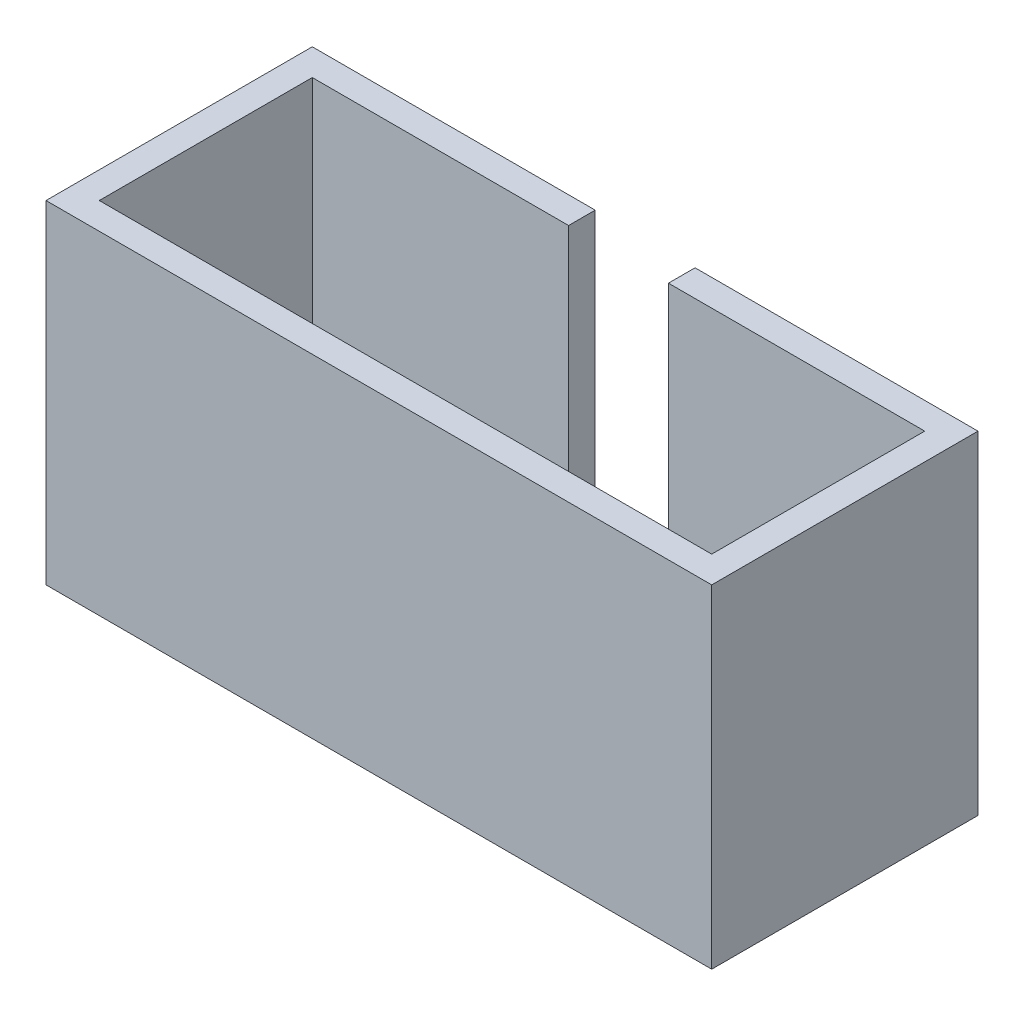
from build123d import *

# Parameters (mm, degrees)
SKETCH1_W           = 20
SKETCH1_H           = 8
SKETCH1_W_2         = 18.4
SKETCH1_H_2         = 6.4
BOSS_EXTRUDE1_DEPTH = 10
SKETCH3_W           = 18.4
SKETCH3_H           = 6.4
BOSS_EXTRUDE2_DEPTH = 0.8
CUT_EXTRUDE1_REACH  = 10
SKETCH2_W           = 3
SKETCH2_H           = 8


with BuildPart() as part:
    # Sketch1 → Boss-Extrude1 (new body)
    with BuildSketch(Plane(origin=(0, 0, 0), x_dir=(1, 0, 0), z_dir=(0, 1, 0))):
        Rectangle(SKETCH1_W, SKETCH1_H)
        Rectangle(SKETCH1_W_2, SKETCH1_H_2, mode=Mode.SUBTRACT)
    extrude(amount=BOSS_EXTRUDE1_DEPTH)

    # Sketch3 → Boss-Extrude2 (add)
    with BuildSketch(Plane(origin=(0, 0, 0), x_dir=(1, 0, 0), z_dir=(0, 1, 0))):
        Rectangle(SKETCH3_W, SKETCH3_H)
    extrude(amount=BOSS_EXTRUDE2_DEPTH)

    # Sketch2 → Cut-Extrude1 (cut, up to next)
    with BuildSketch(Plane.XY.offset(-4), mode=Mode.PRIVATE) as cut_extrude1_sk1:
        with Locations((0, 6)):
            Rectangle(SKETCH2_W, SKETCH2_H)
    cut_extrude1_tool1 = extrude(cut_extrude1_sk1.sketch, amount=CUT_EXTRUDE1_REACH, mode=Mode.PRIVATE) & part.part
    add(cut_extrude1_tool1.solids().sort_by_distance((0, 6, -4))[0], mode=Mode.SUBTRACT)


solid = part.part
